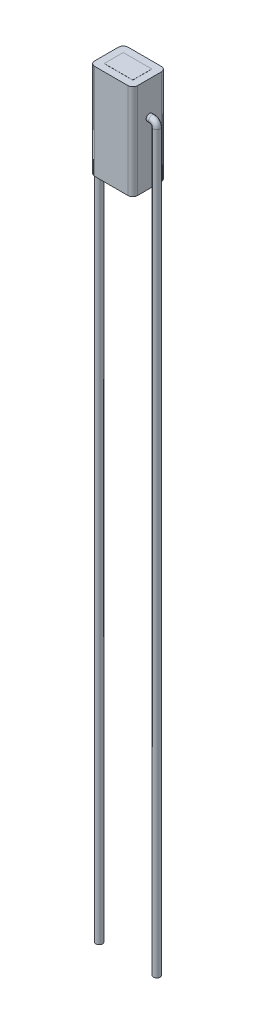
from build123d import *

# Parameters (mm, degrees)
SKETCH1_W                = 4.5
SKETCH1_H                = 3.5
BOSS_EXTRUDE1_DEPTH      = 10
SKETCH2_W                = 3
SKETCH2_H                = 2
BOSS_EXTRUDE2_DEPTH      = 10.01
BOSS_EXTRUDE2_DEPTH_BACK = 0.01
FILLET2_R                = 0.5
SKETCH14_R               = 0.35


with BuildPart() as part:
    # Sketch1 → Boss-Extrude1 (new body)
    with BuildSketch(Plane(origin=(0, 0, 0), x_dir=(1, 0, 0), z_dir=(0, 1, 0))):
        Rectangle(SKETCH1_W, SKETCH1_H)
    extrude(amount=BOSS_EXTRUDE1_DEPTH)

    # Sketch2 → Boss-Extrude2 (add, two sides)
    with BuildSketch(Plane(origin=(0, 0, 0), x_dir=(1, 0, 0), z_dir=(0, 1, 0))) as boss_extrude2_sk:
        Rectangle(SKETCH2_W, SKETCH2_H)
    extrude(amount=BOSS_EXTRUDE2_DEPTH)
    extrude(boss_extrude2_sk.sketch, amount=-BOSS_EXTRUDE2_DEPTH_BACK)

    # Fillet2
    fillet2_edges = [part.edges().sort_by_distance(p)[0] for p in [
        (2.25, 5, 1.75),
        (-2.25, 5, 1.75),
        (-2.25, 5, -1.75),
        (2.25, 5, -1.75),
    ]]
    fillet(fillet2_edges, radius=FILLET2_R)

    # Sweep1: sweep along a path in Sketch15
    with BuildLine(Plane.XY) as sweep1_path:
        Line((2.25, 6.5), (2.3, 6.5))
        Line((2.3, 6.5), (2.525918375, 6.5))
        ThreePointArc((2.525918375, 6.5), (2.879471766, 6.353553391), (3.025918375, 6))
        Line((3.025918375, 6), (3.025918375, -71.146217922))
    # Sketch14 → Sweep1 (sweep)
    with BuildSketch(Plane(origin=(2.25, 0, 0), x_dir=(0, 0, -1), z_dir=(1, 0, 0))):
        with Locations((0, 6.5)):
            Circle(SKETCH14_R)
    sweep1 = sweep(path=sweep1_path.line)

    # Mirror1: Sweep1 across plane
    add(sweep1.mirror(Plane(origin=(0, 0, 0), x_dir=(0, 0, 1), z_dir=(1, 0, 0))))


solid = part.part
